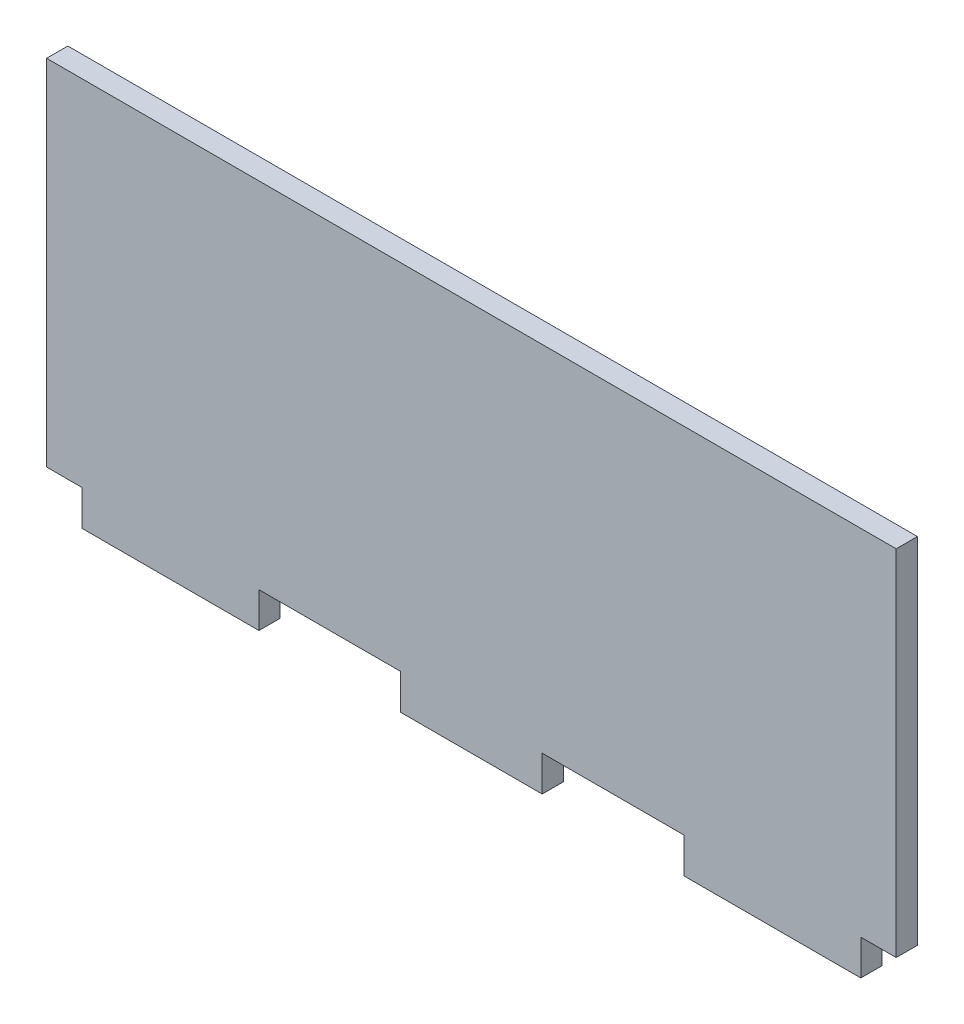
from build123d import *

# Parameters (mm, degrees)
RESSALTO_EXTRUS_O1_DEPTH = 3


with BuildPart() as part:
    # Esboço1 → Ressalto-extrusão1 (new body)
    with BuildSketch(Plane.XY):
        Polygon((-43.490777312, -22.896341463), (-23.490777312, -22.896341463), (-23.490777312, -27.896341463), (-3.490777312, -27.896341463), (-3.490777312, -22.896341463), (16.509222688, -22.896341463), (16.509222688, -27.896341463), (41.509222688, -27.896341463), (41.509222688, -22.896341463), (46.509222688, -22.896341463), (46.509222688, 27.103658537), (-73.490777312, 27.103658537), (-73.490777312, -22.896341463), (-68.490777312, -22.896341463), (-68.490777312, -27.896341463), (-43.490777312, -27.896341463), align=None)
    extrude(amount=RESSALTO_EXTRUS_O1_DEPTH)


solid = part.part
